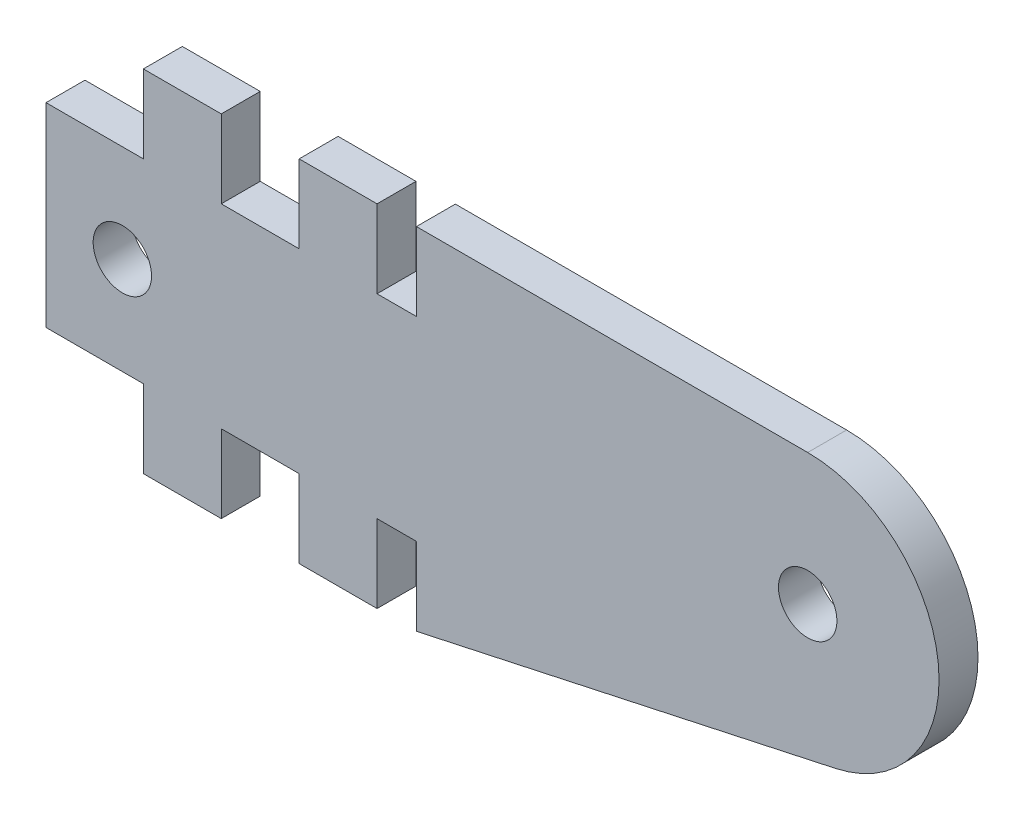
from build123d import *

# Parameters (mm, degrees)
SKETCH1_R           = 1.5
BOSS_EXTRUDE1_DEPTH = 2


with BuildPart() as part:
    # Sketch1 → Boss-Extrude1 (new body)
    with BuildSketch(Plane.XY):
        with BuildLine():
            Line((19.021561934, 0), (40.542646089, 4.662222335))
            ThreePointArc((40.542646089, 4.662222335), (45.821499943, 11.972802233), (39.114495851, 17.999988357))
            Line((39.114495851, 17.999988357), (19.021561934, 17.999988357))
            Line((19.021561934, 17.999988357), (19.021561934, 13.999988357))
            Line((19.021561934, 13.999988357), (17, 13.999988357))
            Line((17, 13.999988357), (17, 17.999988357))
            Line((17, 17.999988357), (13, 17.999988357))
            Line((13, 17.999988357), (13, 13.999988357))
            Line((13, 13.999988357), (9, 13.999988357))
            Line((9, 13.999988357), (9, 17.999988357))
            Line((9, 17.999988357), (5, 17.999988357))
            Line((5, 17.999988357), (5, 13.999988357))
            Line((5, 13.999988357), (0, 13.999988357))
            Line((0, 13.999988357), (0, 4))
            Line((0, 4), (5, 4))
            Line((5, 4), (5, 0))
            Line((5, 0), (9, 0))
            Line((9, 0), (9, 4))
            Line((9, 4), (13, 4))
            Line((13, 4), (13, 0))
            Line((13, 0), (17, 0))
            Line((17, 0), (17, 4))
            Line((17, 4), (19.021561934, 4))
            Line((19.021561934, 4), (19.021561934, 0))
        make_face()
        with Locations((39.114495851, 11.254645274)):
            Circle(SKETCH1_R, mode=Mode.SUBTRACT)
        with Locations((3.920490093, 8.999988357)):
            Circle(SKETCH1_R, mode=Mode.SUBTRACT)
    extrude(amount=BOSS_EXTRUDE1_DEPTH)


solid = part.part
